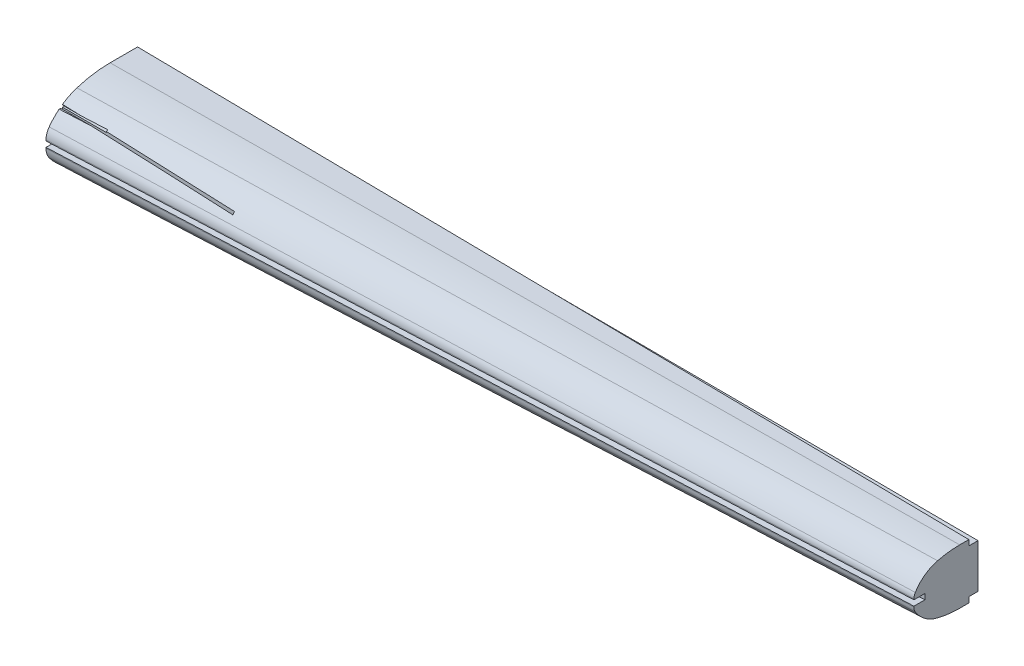
from build123d import *

# Parameters (mm, degrees)
SKETCH4_W          = 55
SKETCH4_H          = 1
CUT_EXTRUDE1_DEPTH = 24
CUT_EXTRUDE2_DEPTH = 94


with BuildPart() as part:
    # Sketch2 → Loft1 section 0
    with BuildSketch(Plane(origin=(0, 0, 0), x_dir=(0, 0, -1), z_dir=(1, 0, 0))):
        with BuildLine():
            Line((55, 14), (55, -14))
            Line((55, -14), (50, -14))
            Line((50, -14), (50, -21))
            Line((50, -21), (35, -21))
            ThreePointArc((35, -21), (25.842604999, -20.29706668), (16.899777934, -18.204737227))
            ThreePointArc((16.899777934, -18.204737227), (8.448934824, -13.968669196), (1.735761871, -7.313270594))
            ThreePointArc((1.735761871, -7.313270594), (0.444938833, -4.794803825), (0, -2))
            Line((0, -2), (0, -1.5))
            Line((0, -1.5), (6, -1.5))
            Line((6, -1.5), (6, 1.5))
            Line((6, 1.5), (0, 1.5))
            Line((0, 1.5), (0, 2))
            ThreePointArc((0, 2), (0.444938833, 4.794803825), (1.735761871, 7.313270594))
            ThreePointArc((1.735761871, 7.313270594), (8.448934824, 13.968669196), (16.899777934, 18.204737227))
            ThreePointArc((16.899777934, 18.204737227), (25.842604999, 20.29706668), (35, 21))
            Line((35, 21), (50, 21))
            Line((50, 21), (50, 14))
            Line((50, 14), (55, 14))
        make_face()
    # Sketch3 → Loft1 section 1
    with BuildSketch(Plane(origin=(454, 0, 0), x_dir=(0, 0, -1), z_dir=(1, 0, 0))):
        with BuildLine():
            Line((55, 12), (55, -12))
            Line((55, -12), (50, -12))
            Line((50, -12), (50, -15))
            Line((50, -15), (45, -15))
            ThreePointArc((45, -15), (38.920867725, -14.629065584), (32.931933824, -13.521766031))
            ThreePointArc((32.931933824, -13.521766031), (25.968880514, -10.268222963), (20.746946568, -4.628980127))
            ThreePointArc((20.746946568, -4.628980127), (20.190360348, -3.366516162), (20, -2))
            Line((20, -2), (20, -1.5))
            Line((20, -1.5), (26, -1.5))
            Line((26, -1.5), (26, 1.5))
            Line((26, 1.5), (20, 1.5))
            Line((20, 1.5), (20, 2))
            ThreePointArc((20, 2), (20.190360348, 3.366516162), (20.746946568, 4.628980127))
            ThreePointArc((20.746946568, 4.628980127), (25.968880514, 10.268222963), (32.931933824, 13.521766031))
            ThreePointArc((32.931933824, 13.521766031), (38.920867725, 14.629065584), (45, 15))
            Line((45, 15), (50, 15))
            Line((50, 15), (50, 12))
            Line((50, 12), (55, 12))
        make_face()
    loft()

    # Sketch4 → Cut-Extrude1 (cut)
    with BuildSketch(Plane(origin=(0, 0, 0), x_dir=(0, 0, -1), z_dir=(1, 0, 0))):
        with Locations((27.5, 13.5)):
            Rectangle(SKETCH4_W, SKETCH4_H)
        with Locations((27.5, -13.5)):
            Rectangle(SKETCH4_W, SKETCH4_H)
    extrude(amount=CUT_EXTRUDE1_DEPTH, mode=Mode.SUBTRACT)

    # Sketch5 → Cut-Extrude2 (cut)
    with BuildSketch(Plane(origin=(0, 0, 0), x_dir=(0, 0, -1), z_dir=(1, 0, 0))):
        Polygon((9, 13), (9, -13), (9, -17.5), (8, -17.5), (8, -13), (8, 13), (8, 17.5), (9, 17.5), align=None)
    extrude(amount=CUT_EXTRUDE2_DEPTH, mode=Mode.SUBTRACT)


solid = part.part
